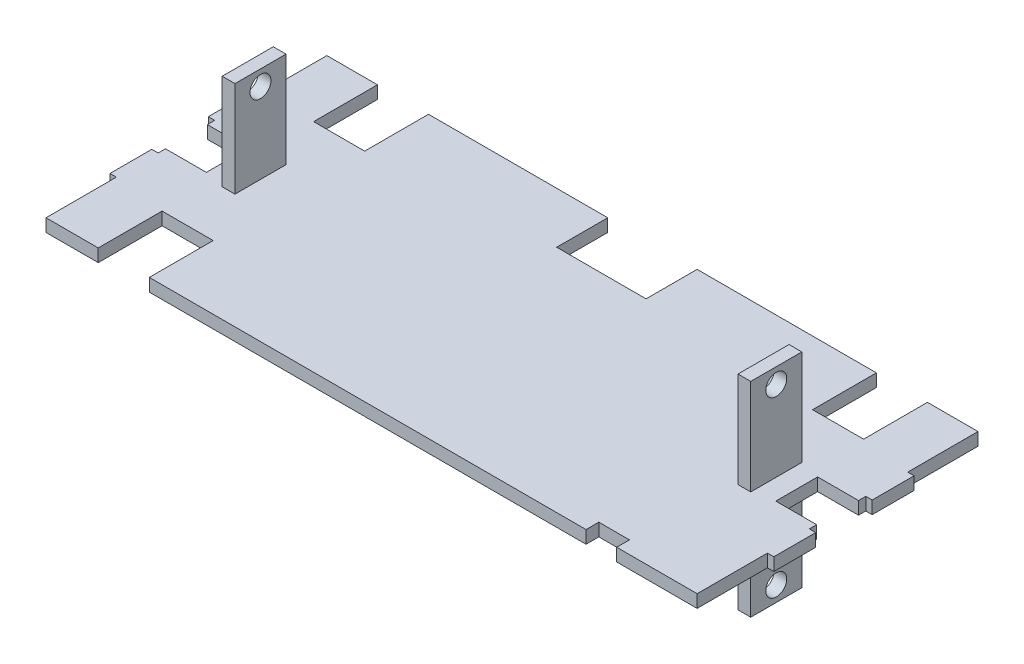
from build123d import *

# Parameters (mm, degrees)
BOSS_EXTRUDE1_DEPTH     = 3.175
SKETCH2_W               = 6.35
SKETCH2_H               = 25.4
BOSS_EXTRUDE2_DEPTH     = 50.8
SKETCH3_R               = 5.207
CUT_EXTRUDE1_DEPTH      = 34.655
CUT_EXTRUDE1_DEPTH_BACK = 297.545


with BuildPart() as part:
    # Sketch1 → Boss-Extrude1 (new body, symmetric)
    with BuildSketch(Plane(origin=(0, 0, 0), x_dir=(1, 0, 0), z_dir=(0, 1, 0))):
        Polygon((161.925, -69.85), (121.92, -69.85), (121.92, -63.5), (106.68, -63.5), (106.68, -69.85), (-106.68, -69.85), (-110.5408, -69.85), (-110.5408, -38.1), (-135.9408, -38.1), (-135.9408, -69.85), (-161.925, -69.85), (-161.925, -34.874677354), (-165.1, -34.874677354), (-165.1, -14.046677354), (-161.925, -14.046677354), (-161.925, -10.414), (-141.605, -10.414), (-141.605, 10.414), (-161.925, 10.414), (-161.925, 14.046677354), (-165.1, 14.046677354), (-165.1, 34.874677354), (-161.925, 34.874677354), (-161.925, 69.85), (-136.779, 69.85), (-136.779, 38.1), (-111.379, 38.1), (-111.379, 69.85), (-22.228595254, 69.85), (-22.228595254, 44.45), (22.228595254, 44.45), (22.228595254, 69.85), (111.379, 69.85), (111.379, 38.1), (136.779, 38.1), (136.779, 69.85), (161.925, 69.85), (161.925, 34.874677354), (165.1, 34.874677354), (165.1, 14.046677354), (161.925, 14.046677354), (161.925, 10.414), (141.605, 10.414), (141.605, -10.414), (161.925, -10.414), (161.925, -14.046677354), (165.1, -14.046677354), (165.1, -34.874677354), (161.925, -34.874677354), align=None)
    extrude(amount=BOSS_EXTRUDE1_DEPTH, both=True)

    # Sketch2 → Boss-Extrude2 (add, symmetric)
    with BuildSketch(Plane(origin=(0, 0, 0), x_dir=(1, 0, 0), z_dir=(0, 1, 0))):
        with Locations((128.27, 0)):
            Rectangle(SKETCH2_W, SKETCH2_H)
        with Locations((-128.27, 0)):
            Rectangle(SKETCH2_W, SKETCH2_H)
    extrude(amount=BOSS_EXTRUDE2_DEPTH, both=True)

    # Sketch3 → Cut-Extrude1 (cut, two sides)
    with BuildSketch(Plane.ZY.offset(131.445)) as cut_extrude1_sk:
        with Locations((0, 43.18)):
            Circle(SKETCH3_R)
        with Locations((0, -43.18)):
            Circle(SKETCH3_R)
    extrude(amount=CUT_EXTRUDE1_DEPTH, mode=Mode.SUBTRACT)
    extrude(cut_extrude1_sk.sketch, amount=-CUT_EXTRUDE1_DEPTH_BACK, mode=Mode.SUBTRACT)


solid = part.part
